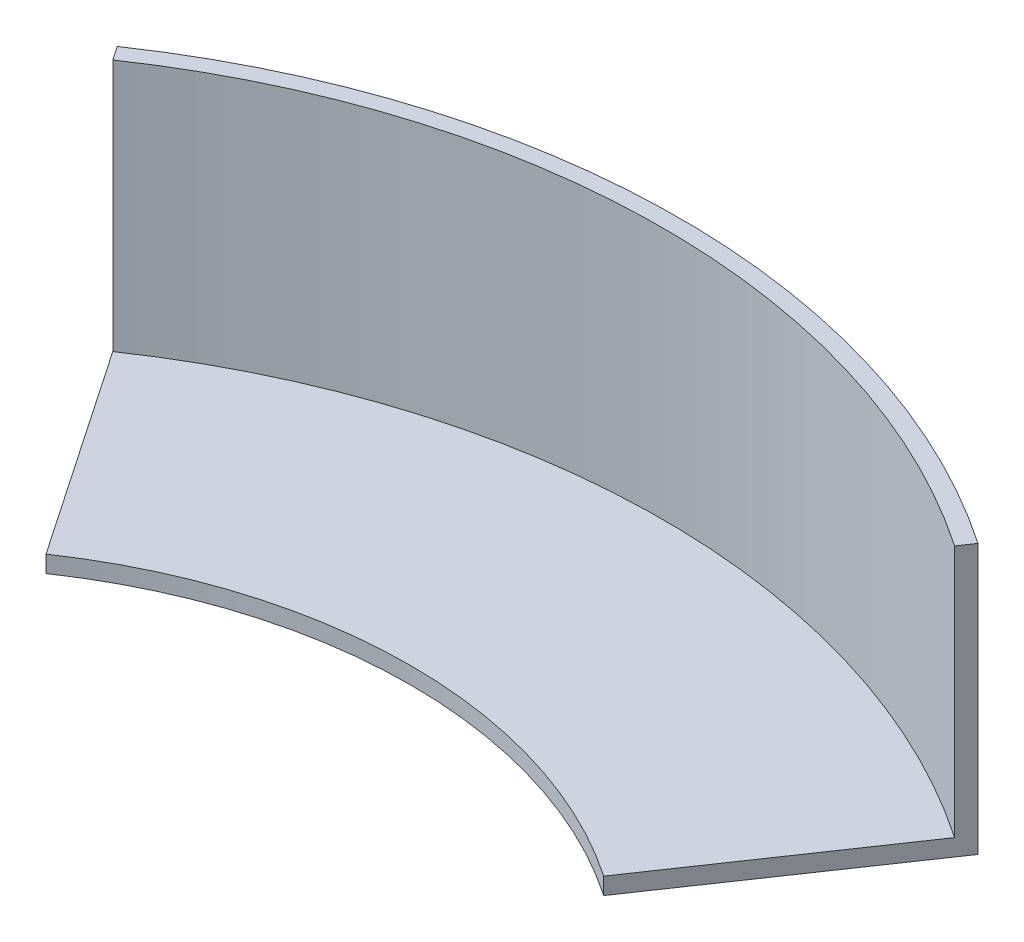
from build123d import *

# Parameters (mm, degrees)
BOSS_EXTRUDE1_DEPTH = 15
SHELL1_T            = 1


with BuildPart() as part:
    # Sketch1 → Boss-Extrude1 (new body)
    with BuildSketch(Plane(origin=(0, 0, 0), x_dir=(1, 0, 0), z_dir=(0, 1, 0))):
        with BuildLine():
            ThreePointArc((25, 36.753265161), (0, 44.45), (-25, 36.753265161))
            Line((-25, 36.753265161), (-16.563554556, 24.350588504))
            ThreePointArc((-16.563554556, 24.350588504), (0, 29.45), (16.563554556, 24.350588504))
            Line((16.563554556, 24.350588504), (25, 36.753265161))
        make_face()
    extrude(amount=BOSS_EXTRUDE1_DEPTH)

    # Shell1
    shell1_openings = [part.faces().sort_by_distance(p)[0] for p in [
        (20.781777278, 7.5, -30.551926832),
        (-20.781777278, 7.5, -30.551926832),
        (0, 7.5, -29.45),
        (0, 15, -35.269418501),
    ]]
    offset(amount=SHELL1_T, openings=shell1_openings, kind=Kind.INTERSECTION)


solid = part.part
